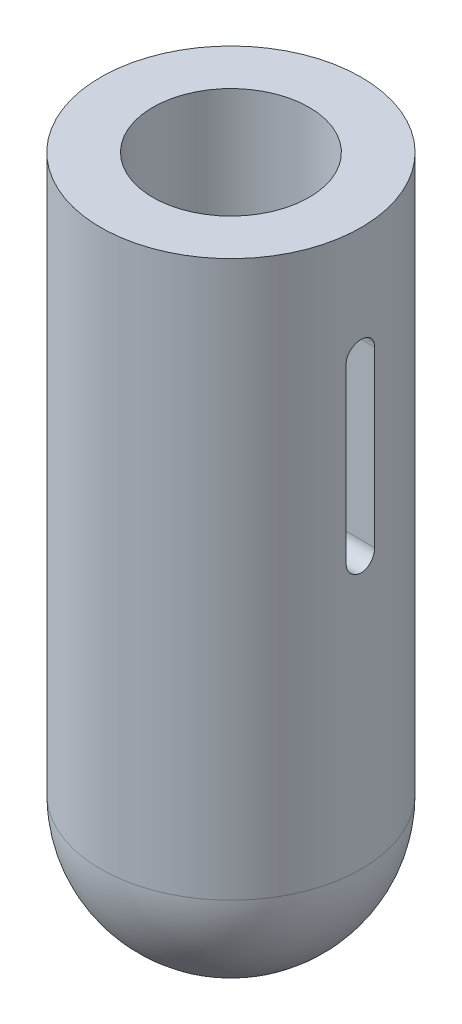
from build123d import *

# Parameters (mm, degrees)
CUT_EXTRUDE1_DEPTH      = 103.248166243
CUT_EXTRUDE1_DEPTH_BACK = 103.248166243


with BuildPart() as part:
    # Sketch1 → Revolve1 (revolve)
    with BuildSketch(Plane(origin=(0, 0, 0), x_dir=(0, 0, -1), z_dir=(1, 0, 0))):
        with BuildLine():
            Line((18.75, 0), (11.25, 0))
            Line((11.25, 0), (11.25, -80))
            Line((11.25, -80), (0, -80))
            Line((0, -80), (0, -98.75))
            ThreePointArc((0, -98.75), (13.258252147, -93.258252147), (18.75, -80))
            Line((18.75, -80), (18.75, 0))
        make_face()
    revolve(axis=Axis((0, -1981.522753143, 0), (0, 1, 0)))

    # Sketch1_3 → Cut-Extrude1 (cut, two sides: drawn at the far end of the back side and taken through both)
    with BuildSketch(Plane(origin=(0, 0, 0), x_dir=(0, 0, -1), z_dir=(1, 0, 0)).offset(-CUT_EXTRUDE1_DEPTH_BACK)):
        with BuildLine():
            Line((2.05, -41), (2.05, -16))
            ThreePointArc((2.05, -16), (0, -13.95), (-2.05, -16))
            Line((-2.05, -16), (-2.05, -41))
            ThreePointArc((-2.05, -41), (0, -43.05), (2.05, -41))
        make_face()
    extrude(amount=CUT_EXTRUDE1_DEPTH + CUT_EXTRUDE1_DEPTH_BACK, mode=Mode.SUBTRACT)


solid = part.part
